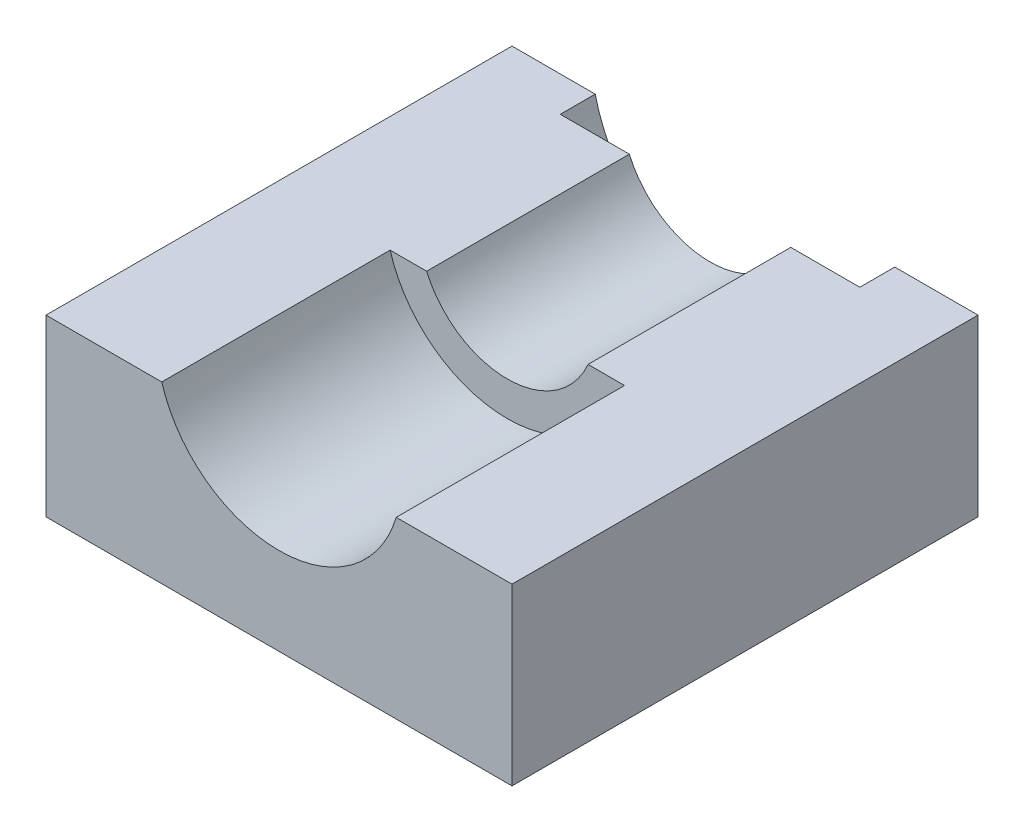
from build123d import *

# Parameters (mm, degrees)
SKETCH1_W           = 200
SKETCH1_H           = 75
BOSS_EXTRUDE1_DEPTH = 200
CUT_EXTRUDE1_START  = -98
SKETCH2_R           = 52.5
CUT_EXTRUDE1_DEPTH  = 98
CUT_EXTRUDE2_START  = -87
SKETCH3_R           = 37.75
CUT_EXTRUDE2_DEPTH  = 87
SKETCH4_R           = 66
CUT_EXTRUDE3_DEPTH  = 200


with BuildPart() as part:
    # Sketch1 → Boss-Extrude1 (new body)
    with BuildSketch(Plane.XY):
        Rectangle(SKETCH1_W, SKETCH1_H)
    extrude(amount=BOSS_EXTRUDE1_DEPTH)

    # Sketch2 → Cut-Extrude1 (cut)
    with BuildSketch(Plane.XY.offset(200).offset(CUT_EXTRUDE1_START)):
        with Locations((-0.000678119, 52.499321881)):
            Circle(SKETCH2_R)
    extrude(amount=CUT_EXTRUDE1_DEPTH, mode=Mode.SUBTRACT)

    # Sketch3 → Cut-Extrude2 (cut)
    with BuildSketch(Plane.XY.offset(102).offset(CUT_EXTRUDE2_START)):
        with Locations((-0.000678119, 52.499321881)):
            Circle(SKETCH3_R)
    extrude(amount=CUT_EXTRUDE2_DEPTH, mode=Mode.SUBTRACT)

    # Sketch4 → Cut-Extrude3 (cut)
    with BuildSketch(Plane.XY.offset(15)):
        with Locations((-0.000678119, 52.499321881)):
            Circle(SKETCH4_R)
    extrude(amount=-CUT_EXTRUDE3_DEPTH, mode=Mode.SUBTRACT)


solid = part.part
